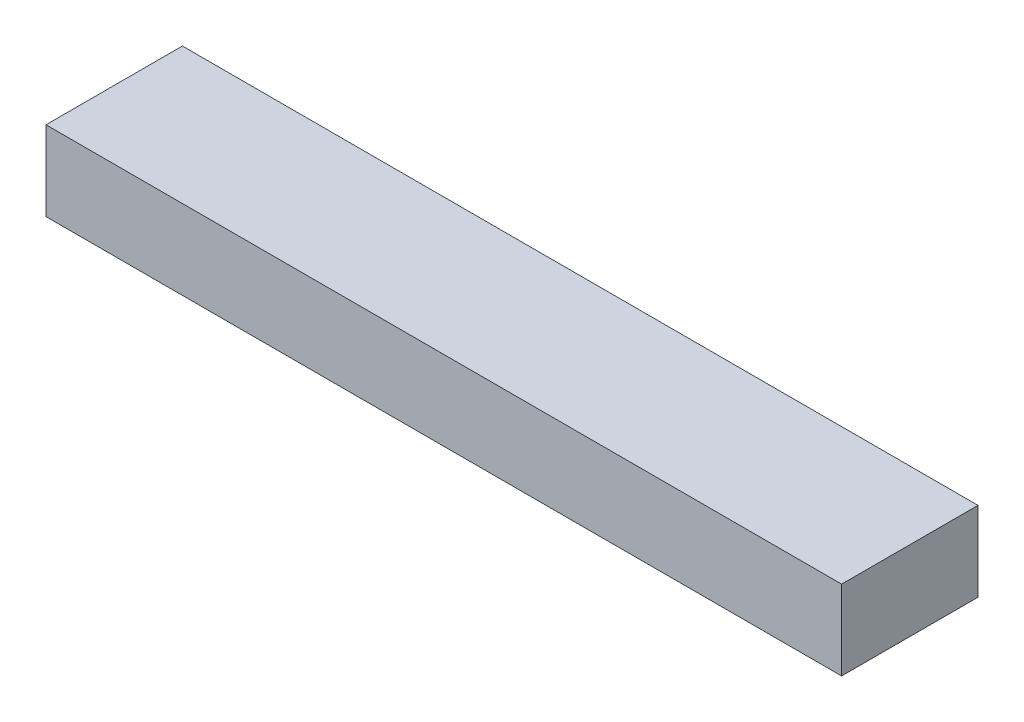
from build123d import *

# Parameters (mm, degrees)
ESQUISSE1_W      = 700
ESQUISSE1_H      = 120
EXTRUSION1_DEPTH = 70


with BuildPart() as part:
    # Esquisse1 → Extrusion1 (new body)
    with BuildSketch(Plane(origin=(0, 0, 0), x_dir=(1, 0, 0), z_dir=(0, 1, 0))):
        with Locations((350, 60)):
            Rectangle(ESQUISSE1_W, ESQUISSE1_H)
    extrude(amount=EXTRUSION1_DEPTH)


solid = part.part
